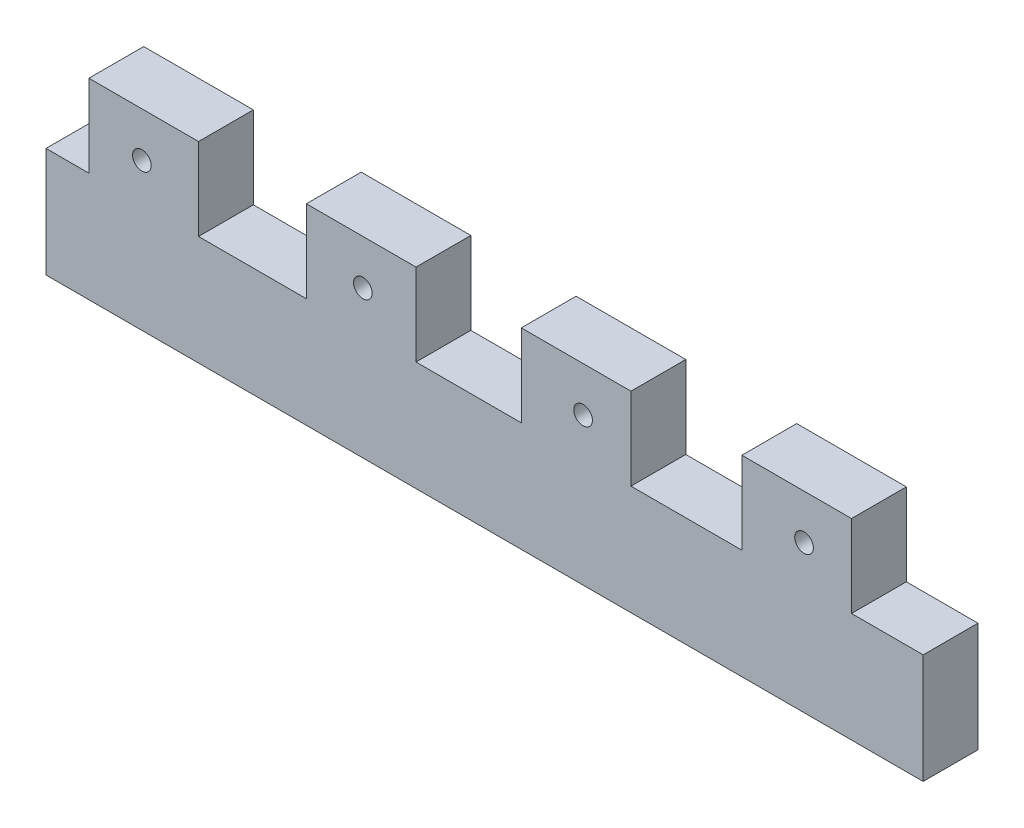
from build123d import *

# Parameters (mm, degrees)
SKETCH2_W           = 12.7
SKETCH2_H           = 9.525
SKETCH2_W_2         = 101.6
SKETCH2_H_2         = 12.7
BOSS_EXTRUDE1_DEPTH = 6.35
SKETCH1_R           = 1.0795
CUT_EXTRUDE2_DEPTH  = 7.35


with BuildPart() as part:
    # Sketch2 → Boss-Extrude1 (new body)
    with BuildSketch(Plane.XY):
        with Locations((11.316373708, 17.4625)):
            Rectangle(SKETCH2_W, SKETCH2_H)
        with Locations((50.8, 6.35)):
            Rectangle(SKETCH2_W_2, SKETCH2_H_2)
        with Locations((36.507855344, 17.4625)):
            Rectangle(SKETCH2_W, SKETCH2_H)
        with Locations((61.401212936, 17.4625)):
            Rectangle(SKETCH2_W, SKETCH2_H)
        with Locations((86.95048554, 17.4625)):
            Rectangle(SKETCH2_W, SKETCH2_H)
    extrude(amount=BOSS_EXTRUDE1_DEPTH)

    # Sketch1 → Cut-Extrude2 (cut, through all)
    with BuildSketch(Plane.XY):
        with Locations((87.798679551, 17.058161716)):
            Circle(SKETCH1_R)
        with Locations((62.206189969, 17.058161716)):
            Circle(SKETCH1_R)
        with Locations((36.698679643, 17.058161716)):
            Circle(SKETCH1_R)
        with Locations((11.106190061, 17.058161716)):
            Circle(SKETCH1_R)
        with Locations((31.326093812, 115.3905236)):
            Circle(SKETCH1_R)
        with Locations((56.918583394, 115.3905236)):
            Circle(SKETCH1_R)
        with Locations((82.42609372, 115.3905236)):
            Circle(SKETCH1_R)
        with Locations((108.018583302, 115.3905236)):
            Circle(SKETCH1_R)
    extrude(amount=CUT_EXTRUDE2_DEPTH, mode=Mode.SUBTRACT)


solid = part.part
